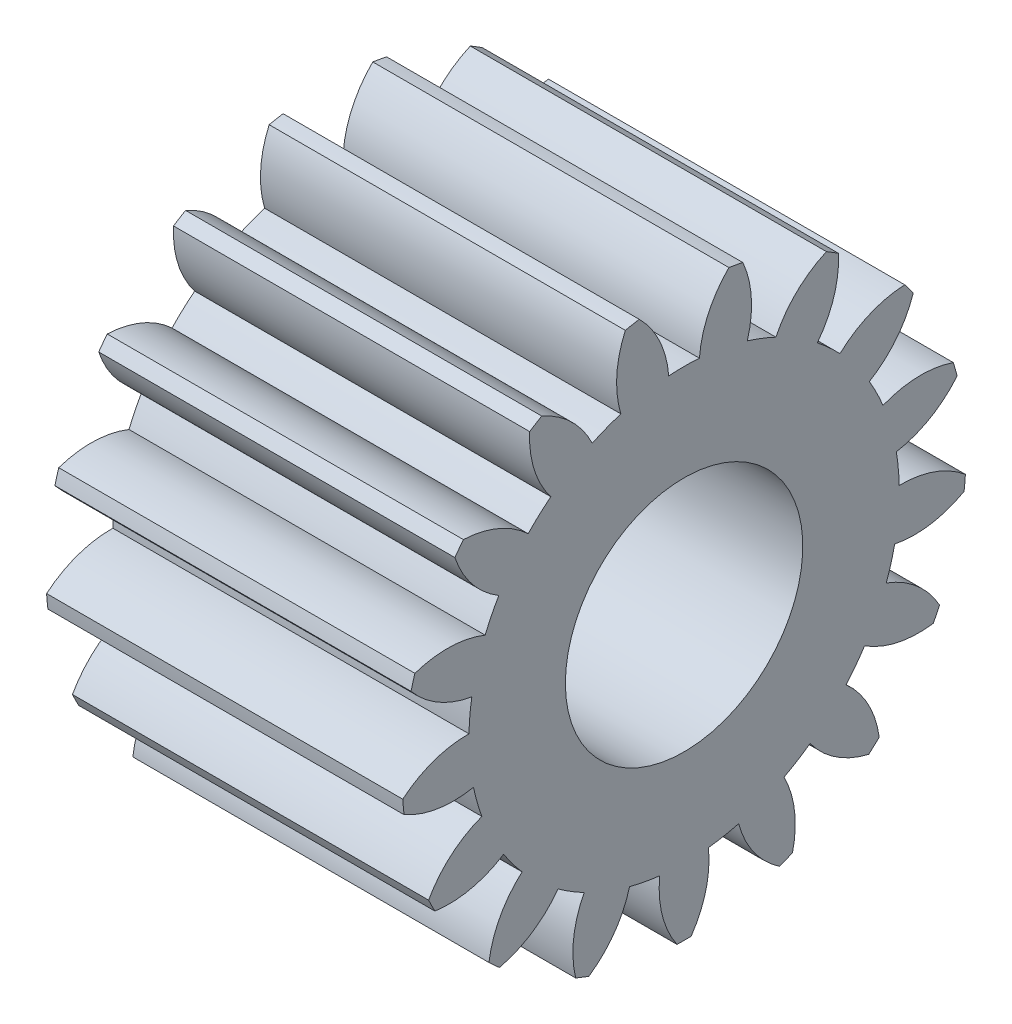
from build123d import *

# Parameters (mm, degrees)
BASPROSKE_W     = 12
BASPROSKE_H     = 9.5
TOOTHCUT_DEPTH  = 19.013883535
TEETHCUTS_COUNT = 17
TEETHCUTS_ANGLE = 338.823529412
BORSKE_R        = 4
BORE_DEPTH      = 50.0000508


with BuildPart() as part:
    # BasProSke → Base-Revolve (revolve)
    with BuildSketch(Plane(origin=(0, 0, 0), x_dir=(1, 0, 0), z_dir=(0, 1, 0)), mode=Mode.PRIVATE) as base_revolve_sk:
        with Locations((6, 4.75)):
            Rectangle(BASPROSKE_W, BASPROSKE_H)
    revolve(base_revolve_sk.sketch.rotate(Axis((-10, 0, 0), (1, 0, 0)), 180), axis=Axis((-10, 0, 0), (1, 0, 0)))

    # TooCutSke → ToothCut (cut, through all)
    with BuildSketch(Plane(origin=(0, 0, 0), x_dir=(0, 0, -1), z_dir=(1, 0, 0))):
        with BuildLine():
            ThreePointArc((0.516861231, 7.23055015), (0, 7.249), (-0.516861231, 7.23055015))
            ThreePointArc((-0.516861231, 7.23055015), (-0.827352654, 8.408398361), (-1.533069197, 9.401220346))
            ThreePointArc((-1.533069197, 9.401220346), (0, 9.5254), (1.533069197, 9.401220346))
            ThreePointArc((1.533069197, 9.401220346), (0.827352654, 8.408398361), (0.516861231, 7.23055015))
        make_face()
    toothcut = extrude(amount=TOOTHCUT_DEPTH, mode=Mode.SUBTRACT)

    # TeethCuts: ToothCut ×17 about axis
    teethcuts_axis = Axis((-10, 0, 0), (1, 0, 0))
    for i in range(1, TEETHCUTS_COUNT):
        add(toothcut.rotate(teethcuts_axis, i * TEETHCUTS_ANGLE / (TEETHCUTS_COUNT - 1)), mode=Mode.SUBTRACT)

    # BorSke → Bore (cut, symmetric)
    with BuildSketch(Plane(origin=(0, 0, 0), x_dir=(0, 0, -1), z_dir=(1, 0, 0))):
        with Locations(Location((0, 0, 0), (0, 0, 180))):
            Circle(BORSKE_R)
    extrude(amount=BORE_DEPTH, both=True, mode=Mode.SUBTRACT)


solid = part.part
